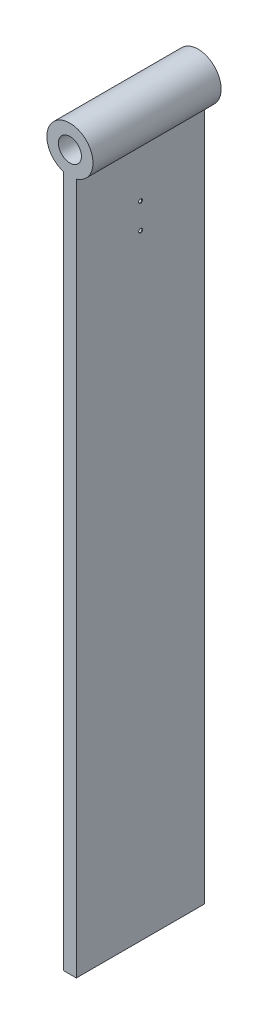
from build123d import *

# Parameters (mm, degrees)
EXTRUDE_1_DEPTH              = 100
SKETCH_2_R                   = 9
CUT_EXTRUDE_1_DEPTH          = 100
HOLE_WIZARD_M3_3_D           = 2.5
HOLE_WIZARD_M3_3_CSINK_D     = 3.05
HOLE_WIZARD_M3_3_CSINK_ANGLE = 90
HOLE_WIZARD_M3_4_D           = 2.5
HOLE_WIZARD_M3_4_CSINK_D     = 3.05
HOLE_WIZARD_M3_4_CSINK_ANGLE = 90


with BuildPart() as part:
    # 草图1 → 凸台-拉伸1 (new body)
    with BuildSketch(Plane.XY):
        with BuildLine():
            Line((0, 0), (5, 0))
            Line((5, 0), (5, 540))
            ThreePointArc((5, 540), (0, 575.291616466), (-5, 540))
            Line((-5, 540), (-5, 0))
            Line((-5, 0), (0, 0))
        make_face()
    extrude(amount=EXTRUDE_1_DEPTH)

    # 草图2 → 切除-拉伸1 (cut)
    with BuildSketch(Plane.XY.offset(100)):
        with Locations((0, 557.291616466)):
            Circle(SKETCH_2_R)
    extrude(amount=-CUT_EXTRUDE_1_DEPTH, mode=Mode.SUBTRACT)

    # M3 螺纹孔3 (through all)
    with Locations(Plane(origin=(5, 500, 49.938905555), x_dir=(0, 0, 1), z_dir=(1, 0, 0))):
        with Locations((0, 0)):
            CounterSinkHole(HOLE_WIZARD_M3_3_D / 2, HOLE_WIZARD_M3_3_CSINK_D / 2, counter_sink_angle=HOLE_WIZARD_M3_3_CSINK_ANGLE)

    # M3 螺纹孔4 (through all)
    with Locations(Plane(origin=(5, 480, 49.890282126), x_dir=(0, 0, 1), z_dir=(1, 0, 0))):
        with Locations((0, 0)):
            CounterSinkHole(HOLE_WIZARD_M3_4_D / 2, HOLE_WIZARD_M3_4_CSINK_D / 2, counter_sink_angle=HOLE_WIZARD_M3_4_CSINK_ANGLE)


solid = part.part
